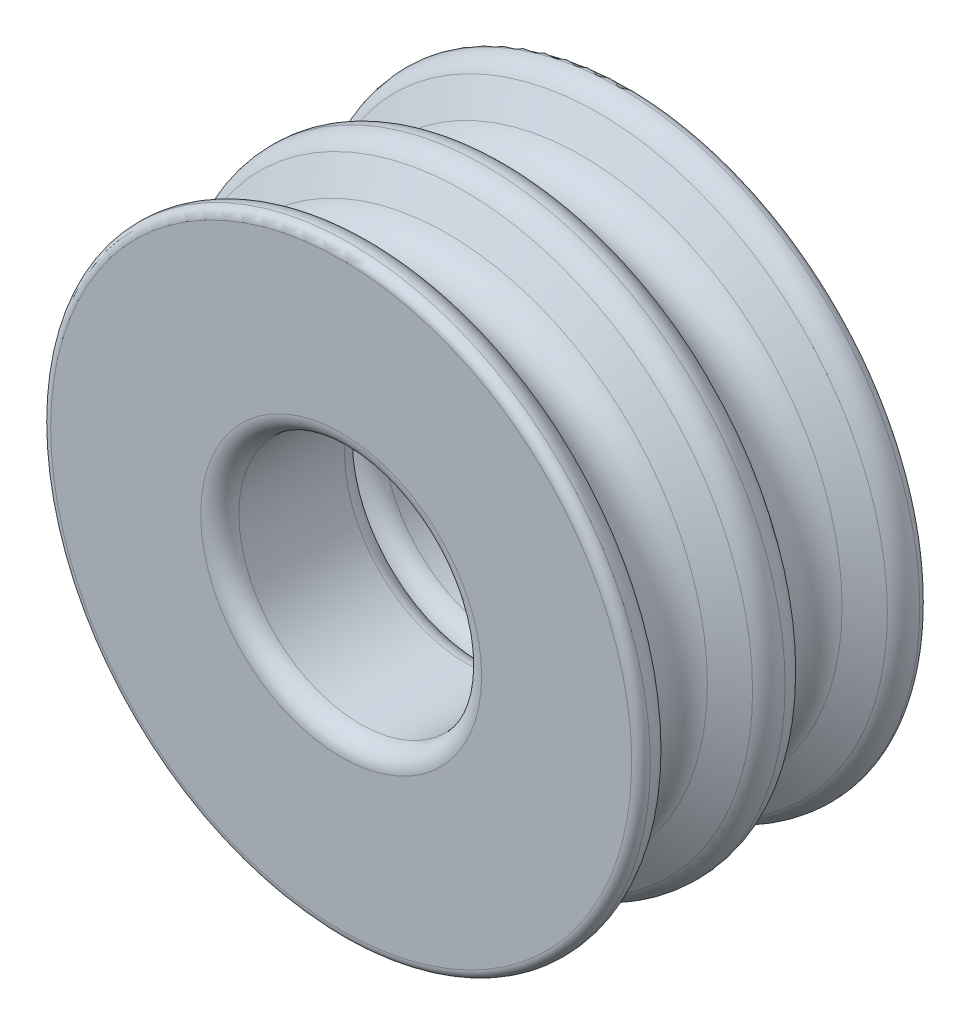
from build123d import *

# Parameters (mm, degrees)
SKETCH2_R          = 6.35
CUT_EXTRUDE1_DEPTH = 8.525021755
FILLET1_R          = 1


with BuildPart() as part:
    # Sketch1 → Revolve1 (revolve)
    with BuildSketch(Plane(origin=(0, 0, 0), x_dir=(0, 0, -1), z_dir=(1, 0, 0))):
        with BuildLine():
            Line((-4, 0), (-4, 15.200626476))
            ThreePointArc((-4, 15.200626476), (-3.86229189, 15.54521984), (-3.525021653, 15.7))
            ThreePointArc((-3.525021653, 15.7), (-2.891169071, 15.555426146), (-2.425739201, 15.101503541))
            Line((-2.425739201, 15.101503541), (-1.558845727, 13.6))
            ThreePointArc((-1.558845727, 13.6), (0, 12.7), (1.558845727, 13.6))
            Line((1.558845727, 13.6), (2.425739201, 15.101503541))
            ThreePointArc((2.425739201, 15.101503541), (2.891169071, 15.555426146), (3.525021653, 15.7))
            Line((3.525021653, 15.7), (3.525021653, 0))
            Line((3.525021653, 0), (-4, 0))
        make_face()
    revolve(axis=Axis((0, 0, 0), (0, 0, 1)))

    # Sketch2 → Cut-Extrude1 (cut, through all)
    with BuildSketch(Plane.XY.offset(4)):
        Circle(SKETCH2_R)
    extrude(amount=-CUT_EXTRUDE1_DEPTH, mode=Mode.SUBTRACT)

    # Fillet1
    fillet1_edges = [part.edges().sort_by_distance(p)[0] for p in [
        (-6.35, 0, -3.525021653),
        (-6.35, 0, 4),
    ]]
    fillet(fillet1_edges, radius=FILLET1_R)

    # Mirror1: part across plane


with BuildPart() as part_1:
    add(part.part)
    add(part.part.mirror(Plane(origin=(0, 0, -3.525021653), x_dir=(1, 0, 0), z_dir=(0, 0, -1))))


solid = part_1.part
